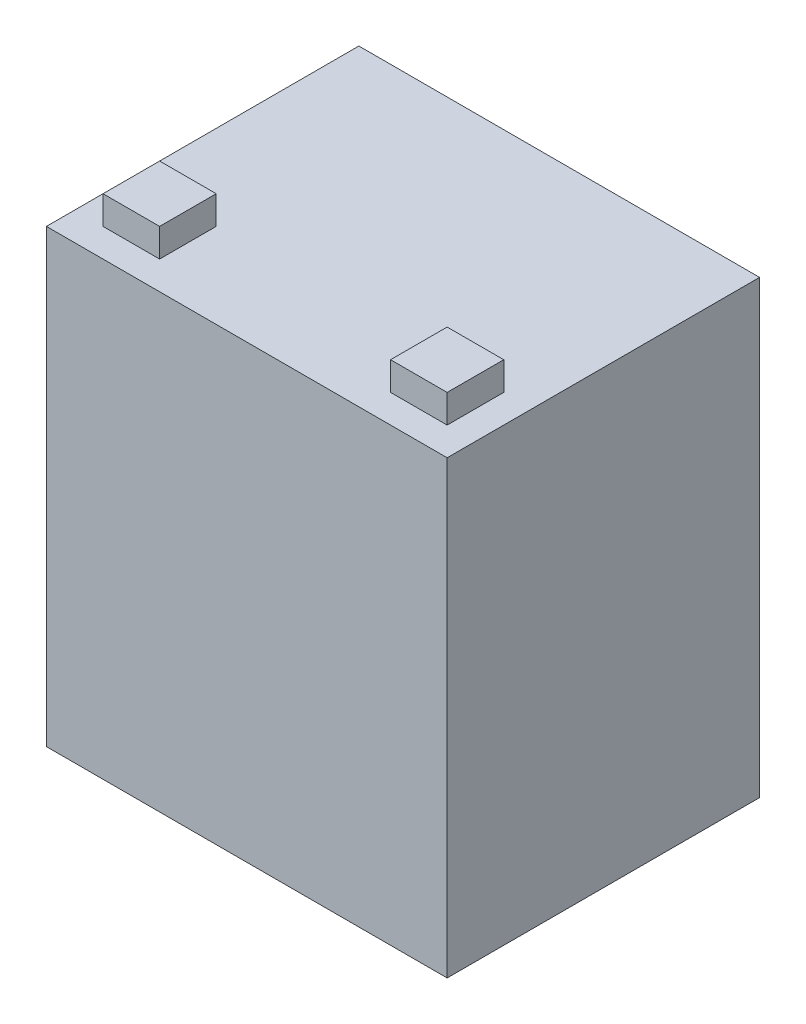
from build123d import *

# Parameters (mm, degrees)
SKETCH1_W           = 89.916
SKETCH1_H           = 70.104
BOSS_EXTRUDE1_DEPTH = 101.092
SKETCH3_W           = 12.7
SKETCH3_H           = 12.7
BOSS_EXTRUDE2_DEPTH = 6.35


with BuildPart() as part:
    # Sketch1 → Boss-Extrude1 (new body)
    with BuildSketch(Plane(origin=(0, 0, 0), x_dir=(1, 0, 0), z_dir=(0, 1, 0))):
        Rectangle(SKETCH1_W, SKETCH1_H)
    extrude(amount=BOSS_EXTRUDE1_DEPTH)

    # Sketch3 → Boss-Extrude2 (add)
    with BuildSketch(Plane(origin=(0, 101.092, 0), x_dir=(1, 0, 0), z_dir=(0, 1, 0))):
        with Locations((32.258, -22.352)):
            Rectangle(SKETCH3_W, SKETCH3_H)
        with Locations((-32.258, -22.352)):
            Rectangle(SKETCH3_W, SKETCH3_H)
    extrude(amount=BOSS_EXTRUDE2_DEPTH)


solid = part.part
